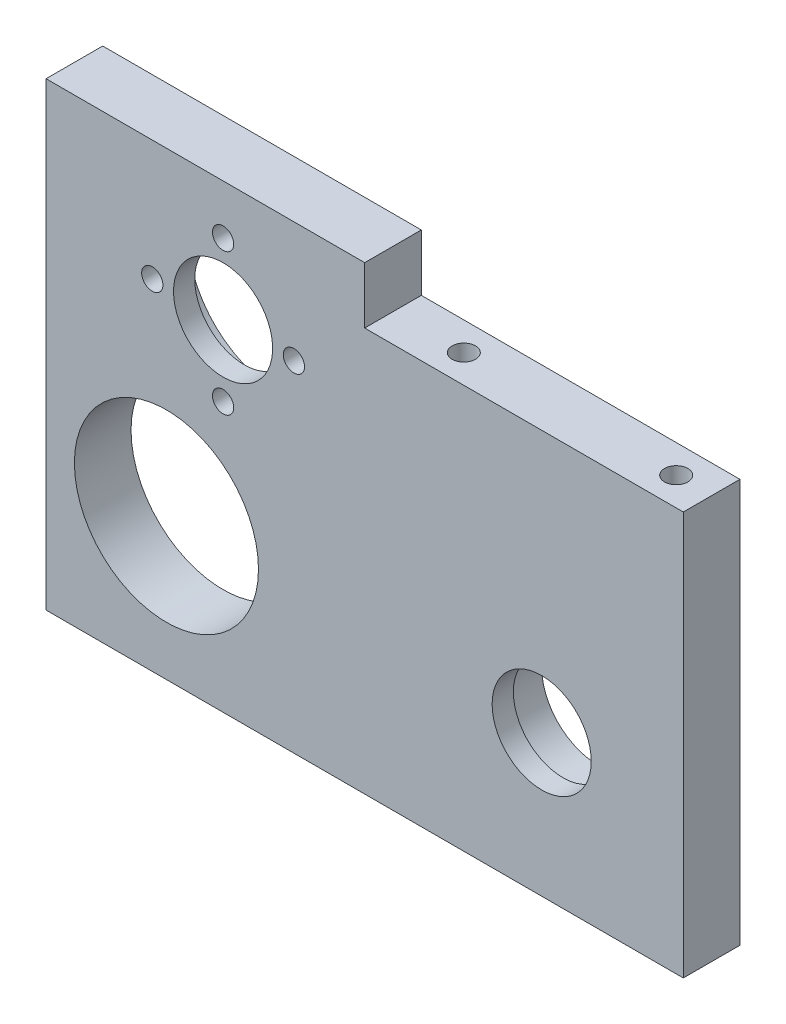
from build123d import *

# Parameters (mm, degrees)
ESQUISSE1_W             = 90
ESQUISSE1_H             = 65
ESQUISSE1_R             = 7
ESQUISSE1_R_2           = 13
BOSS_EXTRU_1_DEPTH      = 8
BOSS_EXTRU_2_START      = -8
ESQUISSE2_R             = 13
BOSS_EXTRU_2_DEPTH      = 3
ESQUISSE3_R             = 7
ESQUISSE3_R_2           = 1.5
ENL_V_MAT_EXTRU_1_DEPTH = 4
ENL_V_START             = -8
ESQUISSE4_R             = 8
ENL_V_MAT_EXTRU_2_DEPTH = 5
ESQUISSE5_W             = 45
ESQUISSE5_H             = 8
ENL_V_MAT_EXTRU_3_DEPTH = 9
ESQUISSE6_R             = 1.65
ENL_V_MAT_EXTRU_4_DEPTH = 10
ESQUISSE7_R             = 1.65
ENL_V_MAT_EXTRU_5_DEPTH = 10


with BuildPart() as part:
    # Esquisse1 → Boss.-Extru.1 (new body)
    with BuildSketch(Plane.XY):
        with Locations((45, 32.5)):
            Rectangle(ESQUISSE1_W, ESQUISSE1_H)
        with Locations((70, 20)):
            Circle(ESQUISSE1_R, mode=Mode.SUBTRACT)
        with Locations((17, 20)):
            Circle(ESQUISSE1_R_2, mode=Mode.SUBTRACT)
        with Locations((25, 48)):
            Circle(ESQUISSE1_R_2, mode=Mode.SUBTRACT)
    extrude(amount=BOSS_EXTRU_1_DEPTH)

    # Esquisse2 → Boss.-Extru.2 (add)
    with BuildSketch(Plane(origin=(0, 0, 0), x_dir=(-1, 0, 0), z_dir=(0, 0, -1)).offset(BOSS_EXTRU_2_START)):
        with Locations((-25, 48)):
            Circle(ESQUISSE2_R)
    extrude(amount=BOSS_EXTRU_2_DEPTH)

    # Esquisse3 → Enlèv. mat.-Extru.1 (cut, through all)
    with BuildSketch(Plane(origin=(0, 0, 5), x_dir=(-1, 0, 0), z_dir=(0, 0, -1))):
        with Locations((-25, 48)):
            Circle(ESQUISSE3_R)
        with Locations((-15, 48)):
            Circle(ESQUISSE3_R_2)
        with Locations((-25, 38)):
            Circle(ESQUISSE3_R_2)
        with Locations((-35, 48)):
            Circle(ESQUISSE3_R_2)
        with Locations((-25, 58)):
            Circle(ESQUISSE3_R_2)
    extrude(amount=-ENL_V_MAT_EXTRU_1_DEPTH, mode=Mode.SUBTRACT)

    # Esquisse4 → Enlèv. mat.-Extru.2 (cut)
    with BuildSketch(Plane.XY.offset(8).offset(ENL_V_START)):
        with Locations((70, 20)):
            Circle(ESQUISSE4_R)
    extrude(amount=ENL_V_MAT_EXTRU_2_DEPTH, mode=Mode.SUBTRACT)

    # Esquisse5 → Enlèv. mat.-Extru.3 (cut, through all)
    with BuildSketch(Plane(origin=(0, 0, 0), x_dir=(-1, 0, 0), z_dir=(0, 0, -1))):
        with Locations((-67.5, 61)):
            Rectangle(ESQUISSE5_W, ESQUISSE5_H)
    extrude(amount=-ENL_V_MAT_EXTRU_3_DEPTH, mode=Mode.SUBTRACT)

    # Esquisse6 → Enlèv. mat.-Extru.4 (cut)
    with BuildSketch(Plane.ZY):
        with Locations((4, 45)):
            Circle(ESQUISSE6_R)
        with Locations((4, 7)):
            Circle(ESQUISSE6_R)
    extrude(amount=-ENL_V_MAT_EXTRU_4_DEPTH, mode=Mode.SUBTRACT)

    # Esquisse7 → Enlèv. mat.-Extru.5 (cut)
    with BuildSketch(Plane(origin=(0, 57, 0), x_dir=(1, 0, 0), z_dir=(0, 1, 0))):
        with Locations((85, -4)):
            Circle(ESQUISSE7_R)
        with Locations((55, -4)):
            Circle(ESQUISSE7_R)
    extrude(amount=-ENL_V_MAT_EXTRU_5_DEPTH, mode=Mode.SUBTRACT)


solid = part.part
